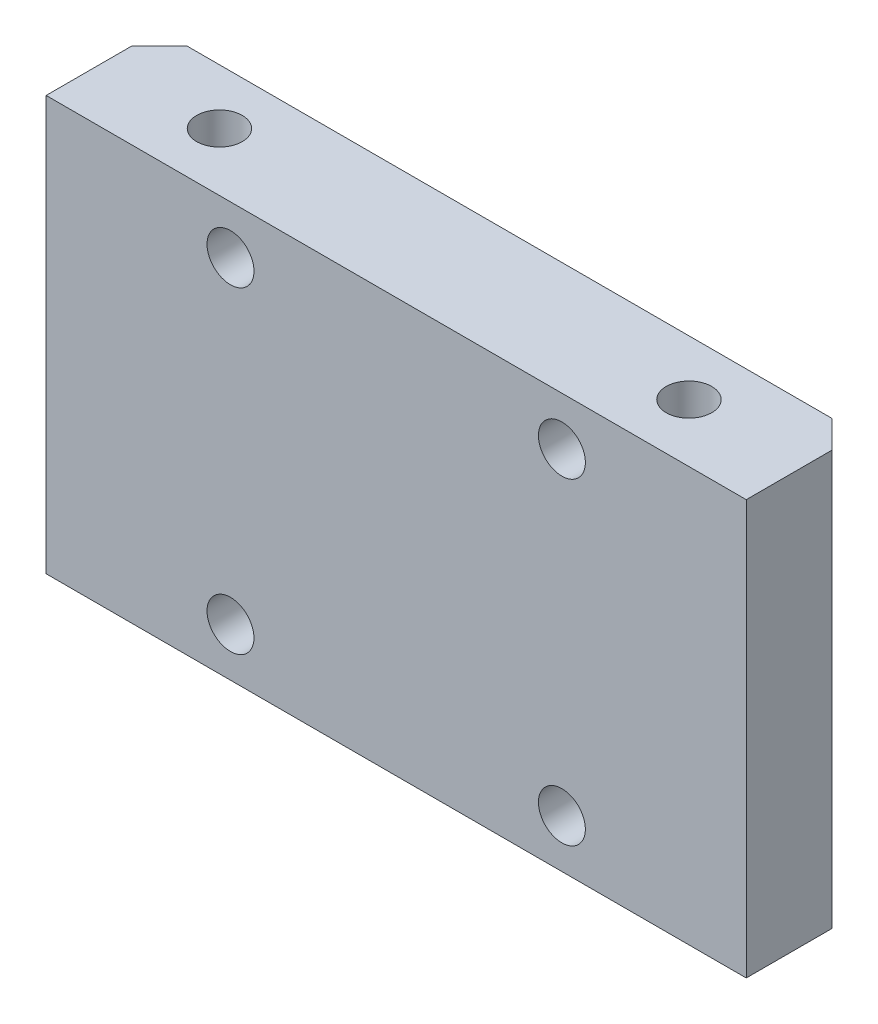
from build123d import *

# Parameters (mm, degrees)
SKETCH_1_W                  = 50.700001454
SKETCH_1_H                  = 30.000001519
EXTRUDE_1_DEPTH             = 8.20000004
HOLE_WIZARD_3_3_3_3_1_D     = 3.300000535
HOLE_WIZARD_3_3_3_3_1_DEPTH = 30.00000152
HOLE_WIZARD_3_4_3_4_1_D     = 3.4
HOLE_WIZARD_3_4_3_4_1_DEPTH = 8.20000004
HOLE_WIZARD_3_4_3_4_2_D     = 3.4
HOLE_WIZARD_3_4_3_4_2_DEPTH = 8.20000004
CHAMFER_1_SIZE              = 1.8
CHAMFER_2_SIZE2             = 2.000000328
CHAMFER_2_SIZE              = 2.000000095


with BuildPart() as part:
    # 草图1 → 凸台-拉伸1 (new body)
    with BuildSketch(Plane(origin=(0, 0, 449.800000759), x_dir=(-1, 0, 0), z_dir=(0, 0, -1))):
        with Locations((-260.000000326, 239.999999943)):
            Rectangle(SKETCH_1_W, SKETCH_1_H)
    extrude(amount=-EXTRUDE_1_DEPTH)

    # Ø3.3 (3.3) 直径孔1
    with Locations(Plane(origin=(0, 224.999999183, 0), x_dir=(-1, 0, 0), z_dir=(0, -1, 0))):
        with Locations((-277.000001292, -453.79999995), (-243.000000389, -453.799999743)):
            Hole(HOLE_WIZARD_3_3_3_3_1_D / 2, depth=HOLE_WIZARD_3_3_3_3_1_DEPTH)

    # Ø3.4 (3.4) 直径孔1
    with Locations(Plane(origin=(0, 0, 449.800000759), x_dir=(-1, 0, 0), z_dir=(0, 0, -1))):
        with Locations((-272, 251.5), (-272, 228.5)):
            Hole(HOLE_WIZARD_3_4_3_4_1_D / 2, depth=HOLE_WIZARD_3_4_3_4_1_DEPTH)

    # Ø3.4 (3.4) 直径孔2
    with Locations(Plane.XY.offset(458.0000008)):
        with Locations((248, 251.5), (248, 228.5)):
            Hole(HOLE_WIZARD_3_4_3_4_2_D / 2, depth=HOLE_WIZARD_3_4_3_4_2_DEPTH)

    # 倒角1
    chamfer_1_edges = [part.edges().sort_by_distance(p)[0] for p in [
        (270.3, 228.5, 449.800000759),
        (270.3, 251.5, 449.800000759),
        (249.7, 228.5, 449.80000076),
        (249.7, 251.5, 449.80000076),
    ]]
    chamfer(chamfer_1_edges, length=CHAMFER_1_SIZE)

    # 倒角2
    chamfer_2_edges = [part.edges().sort_by_distance(p)[0] for p in [
        (234.649999599, 239.999999942, 449.800000759),
        (285.350001053, 239.999999942, 449.800000759),
    ]]
    chamfer(chamfer_2_edges, length=CHAMFER_2_SIZE, length2=CHAMFER_2_SIZE2)


solid = part.part
